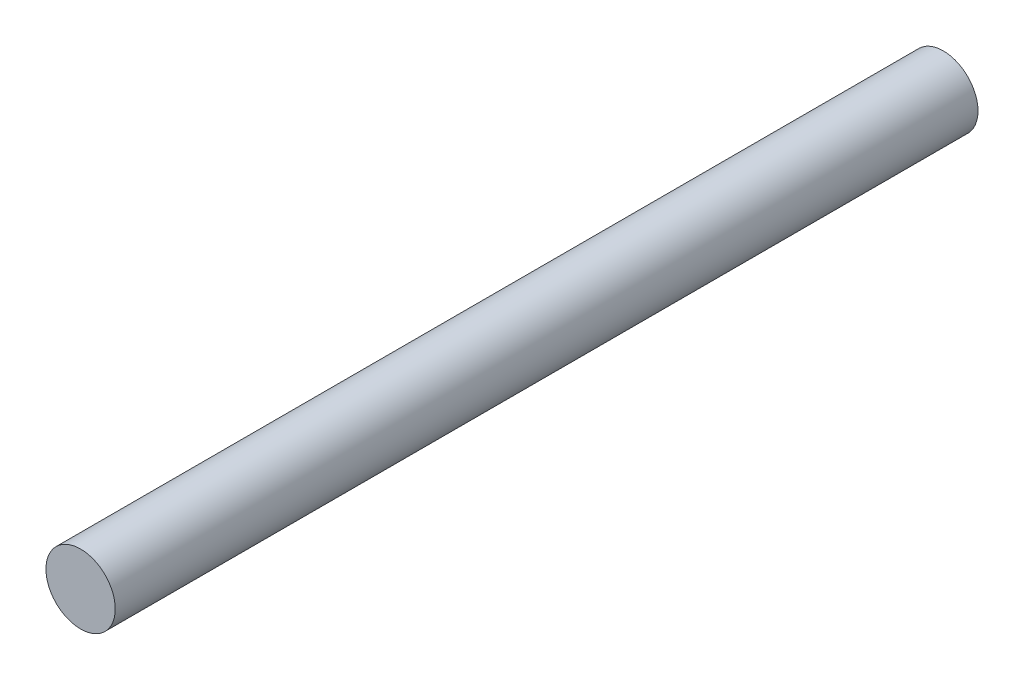
from build123d import *

# Parameters (mm, degrees)
SKETCH1_R           = 4
BOSS_EXTRUDE1_DEPTH = 99.568


with BuildPart() as part:
    # Sketch1 → Boss-Extrude1 (new body)
    with BuildSketch(Plane.XY):
        Circle(SKETCH1_R)
    extrude(amount=BOSS_EXTRUDE1_DEPTH)


solid = part.part
